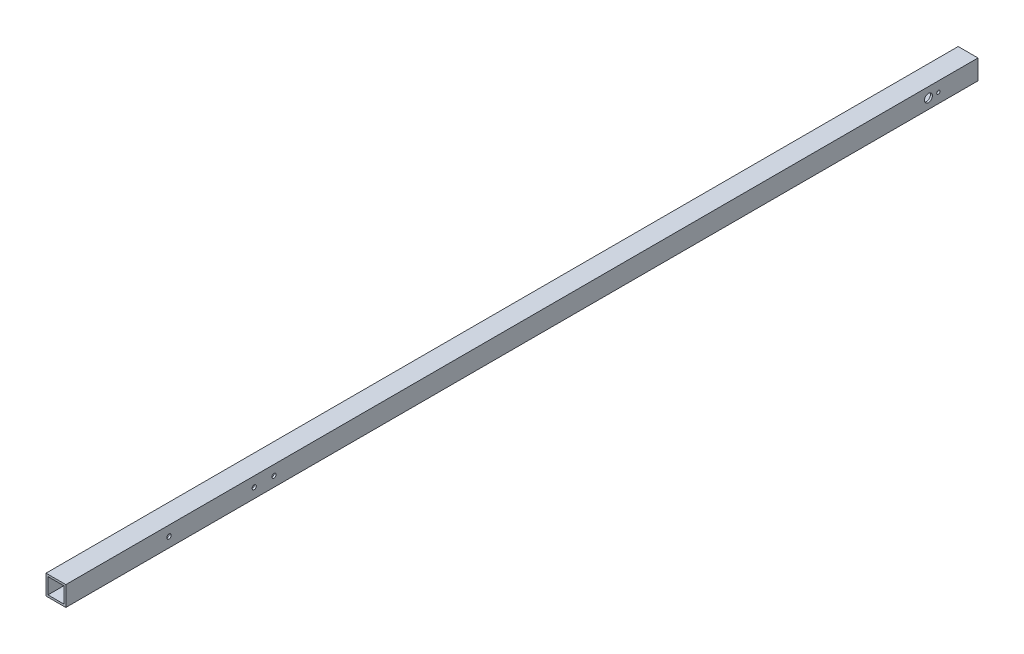
from build123d import *

# Parameters (mm, degrees)
SKETCH_1_W          = 20
SKETCH_1_H          = 20
SKETCH_1_W_2        = 16
SKETCH_1_H_2        = 16
EXTRUDE_1_DEPTH     = 970
SKETCH_2_R          = 4.05
CUT_EXTRUDE_1_DEPTH = 20
SKETCH_4_W          = 21.376287738
SKETCH_4_H          = 29.089038522
CUT_EXTRUDE_3_DEPTH = 50
SKETCH_5_R          = 2.2
CUT_EXTRUDE_4_DEPTH = 30
SKETCH_6_R          = 1
CUT_EXTRUDE_5_DEPTH = 10
M4X0_7_1_D          = 3.3
M4X0_7_1_DEPTH      = 11.5
M4X0_7_1_TIP        = 0.991420021
SKETCH_12_R         = 1
CUT_EXTRUDE_7_DEPTH = 10
M4X0_7_6_D          = 3.3
M4X0_7_6_DEPTH      = 11.5
M4X0_7_6_TIP        = 0.991420021
SKETCH_15_R         = 2.1
CUT_EXTRUDE_8_DEPTH = 21
SKETCH_16_R         = 1
CUT_EXTRUDE_9_DEPTH = 10
M4X0_7_7_D          = 3.3
M4X0_7_7_DEPTH      = 11.5
M4X0_7_7_TIP        = 0.991420021


with BuildPart() as part:
    # ｽｹｯﾁ1 → ﾎﾞｽ - 押し出し1 (new body)
    with BuildSketch(Plane.XY):
        Rectangle(SKETCH_1_W, SKETCH_1_H)
        Rectangle(SKETCH_1_W_2, SKETCH_1_H_2, mode=Mode.SUBTRACT)
    extrude(amount=EXTRUDE_1_DEPTH)

    # ｽｹｯﾁ2 → ｶｯﾄ - 押し出し1 (cut)
    with BuildSketch(Plane(origin=(10, 0, 0), x_dir=(0, 0, -1), z_dir=(1, 0, 0))):
        with Locations((-50, 0)):
            Circle(SKETCH_2_R)
    extrude(amount=-CUT_EXTRUDE_1_DEPTH, mode=Mode.SUBTRACT)

    # ｽｹｯﾁ4 → ｶｯﾄ - 押し出し3 (cut)
    with BuildSketch(Plane.XY.offset(970)):
        Rectangle(SKETCH_4_W, SKETCH_4_H)
    extrude(amount=-CUT_EXTRUDE_3_DEPTH, mode=Mode.SUBTRACT)

    # ｽｹｯﾁ5 → ｶｯﾄ - 押し出し4 (cut)
    with BuildSketch(Plane(origin=(10, 0, 0), x_dir=(0, 0, -1), z_dir=(1, 0, 0))):
        with Locations((-816, 0)):
            Circle(SKETCH_5_R)
    extrude(amount=-CUT_EXTRUDE_4_DEPTH, mode=Mode.SUBTRACT)

    # ｽｹｯﾁ6 → ｶｯﾄ - 押し出し5 (cut)
    with BuildSketch(Plane.XZ.offset(10)):
        with Locations((0, 30)):
            Circle(SKETCH_6_R)
        with Locations((0, 50)):
            Circle(SKETCH_6_R)
    extrude(amount=-CUT_EXTRUDE_5_DEPTH, mode=Mode.SUBTRACT)

    # M4x0.7 ねじ穴1
    with Locations(Plane(origin=(0, -10, 30), x_dir=(0, 0, -1), z_dir=(0, -1, 0))):
        with Locations((0, 0), (-20, 0)):
            Hole(M4X0_7_1_D / 2, depth=M4X0_7_1_DEPTH)
            with Locations((0, 0, -(M4X0_7_1_DEPTH + M4X0_7_1_TIP / 2))):  # 118° drill point
                Cone(0, M4X0_7_1_D / 2, M4X0_7_1_TIP, mode=Mode.SUBTRACT)

    # ｽｹｯﾁ12 → ｶｯﾄ - 押し出し7 (cut)
    with BuildSketch(Plane(origin=(10, 0, 0), x_dir=(0, 0, -1), z_dir=(1, 0, 0))):
        with Locations((-40, 0)):
            Circle(SKETCH_12_R)
        with Locations((-710, 0)):
            Circle(SKETCH_12_R)
        with Locations((-730, 0)):
            Circle(SKETCH_12_R)
    extrude(amount=-CUT_EXTRUDE_7_DEPTH, mode=Mode.SUBTRACT)

    # M4x0.7 ねじ穴6
    with Locations(Plane(origin=(10, 0, 40), x_dir=(0, 0, 1), z_dir=(1, 0, 0))):
        with Locations((0, 0)):
            Hole(M4X0_7_6_D / 2, depth=M4X0_7_6_DEPTH)
            with Locations((0, 0, -(M4X0_7_6_DEPTH + M4X0_7_6_TIP / 2))):  # 118° drill point
                Cone(0, M4X0_7_6_D / 2, M4X0_7_6_TIP, mode=Mode.SUBTRACT)

    # ｽｹｯﾁ15 → ｶｯﾄ - 押し出し8 (cut, through all)
    with BuildSketch(Plane(origin=(10, 0, 0), x_dir=(0, 0, -1), z_dir=(1, 0, 0))):
        with Locations((-710, 0)):
            Circle(SKETCH_15_R)
        with Locations((-730, 0)):
            Circle(SKETCH_15_R)
    extrude(amount=-CUT_EXTRUDE_8_DEPTH, mode=Mode.SUBTRACT)

    # ｽｹｯﾁ16 → ｶｯﾄ - 押し出し9 (cut)
    with BuildSketch(Plane(origin=(0, -10, 0), x_dir=(-1, 0, 0), z_dir=(0, -1, 0))):
        with Locations((0, -670)):
            Circle(SKETCH_16_R)
        with Locations((0, -650)):
            Circle(SKETCH_16_R)
    extrude(amount=-CUT_EXTRUDE_9_DEPTH, mode=Mode.SUBTRACT)

    # M4x0.7 ねじ穴7
    with Locations(Plane(origin=(0, -10, 670), x_dir=(0, 0, -1), z_dir=(0, -1, 0))):
        with Locations((0, 0), (20, 0)):
            Hole(M4X0_7_7_D / 2, depth=M4X0_7_7_DEPTH)
            with Locations((0, 0, -(M4X0_7_7_DEPTH + M4X0_7_7_TIP / 2))):  # 118° drill point
                Cone(0, M4X0_7_7_D / 2, M4X0_7_7_TIP, mode=Mode.SUBTRACT)


solid = part.part
